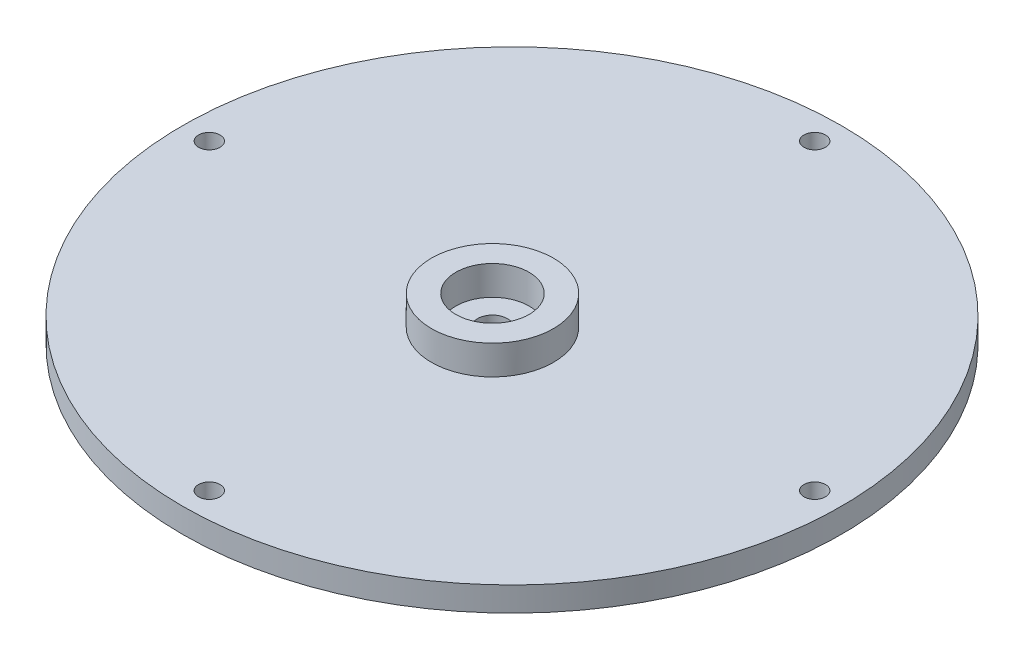
from build123d import *

# Parameters (mm, degrees)
SKETCH2_R           = 12.5
SKETCH2_R_2         = 7.5
BOSS_EXTRUDE1_DEPTH = 6
SKETCH3_R           = 10.5
CUT_EXTRUDE1_DEPTH  = 3
SKETCH4_R           = 3.05
CUT_EXTRUDE2_DEPTH  = 11
SKETCH5_R           = 2.2
CUT_EXTRUDE3_DEPTH  = 11
SKETCH6_R           = 57
SKETCH6_R_2         = 54
CUT_EXTRUDE4_DEPTH  = 2


with BuildPart() as part:
    # Sketch1 → Revolve1 (revolve)
    with BuildSketch(Plane.XY):
        Polygon((0, 0), (-67.5, 0), (-67.5, -5), (-50, -5), (-50, -10), (0, -10), align=None)
    revolve(axis=Axis((0, -10, 0), (0, 1, 0)))

    # Sketch2 → Boss-Extrude1 (add)
    with BuildSketch(Plane(origin=(0, 0, 0), x_dir=(1, 0, 0), z_dir=(0, 1, 0))):
        with Locations((0, -4)):
            Circle(SKETCH2_R)
        with Locations((0, -4)):
            Circle(SKETCH2_R_2, mode=Mode.SUBTRACT)
    extrude(amount=BOSS_EXTRUDE1_DEPTH)

    # Sketch3 → Cut-Extrude1 (cut)
    with BuildSketch(Plane.XZ.offset(10)):
        with Locations((0, 4)):
            Circle(SKETCH3_R)
    extrude(amount=-CUT_EXTRUDE1_DEPTH, mode=Mode.SUBTRACT)

    # Sketch4 → Cut-Extrude2 (cut, through all)
    with BuildSketch(Plane(origin=(0, 0, 0), x_dir=(1, 0, 0), z_dir=(0, 1, 0))):
        with Locations((0, -4)):
            Circle(SKETCH4_R)
    extrude(amount=-CUT_EXTRUDE2_DEPTH, mode=Mode.SUBTRACT)

    # Sketch5 → Cut-Extrude3 (cut, through all)
    with BuildSketch(Plane(origin=(0, 0, 0), x_dir=(1, 0, 0), z_dir=(0, 1, 0))):
        with Locations((0, 62)):
            Circle(SKETCH5_R)
        with Locations((62, 0)):
            Circle(SKETCH5_R)
        with Locations((0, -62)):
            Circle(SKETCH5_R)
        with Locations((-62, 0)):
            Circle(SKETCH5_R)
    extrude(amount=-CUT_EXTRUDE3_DEPTH, mode=Mode.SUBTRACT)

    # Sketch6 → Cut-Extrude4 (cut)
    with BuildSketch(Plane.XZ.offset(5)):
        Circle(SKETCH6_R)
        Circle(SKETCH6_R_2, mode=Mode.SUBTRACT)
    extrude(amount=-CUT_EXTRUDE4_DEPTH, mode=Mode.SUBTRACT)


solid = part.part
